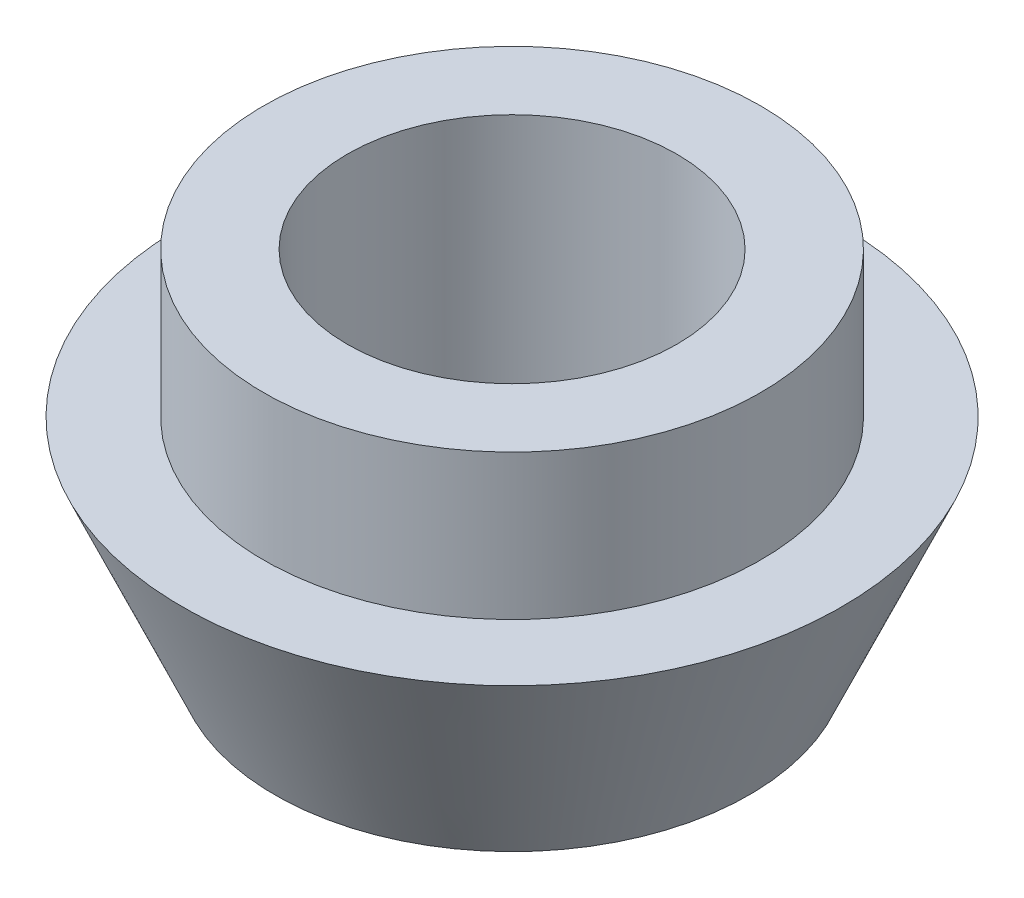
from build123d import *


with BuildPart() as part:
    # Sketch1 → Revolve1 (revolve)
    with BuildSketch(Plane.XY):
        Polygon((3.175, 0), (3.175, 6.8199), (3.96875, 6.8199), (4.7879, 6.8199), (4.7879, 4.0259), (6.35, 4.0259), (4.572, 0), align=None)
    revolve(axis=Axis((0, -15.087860977, 0), (0, 1, 0)))


solid = part.part
